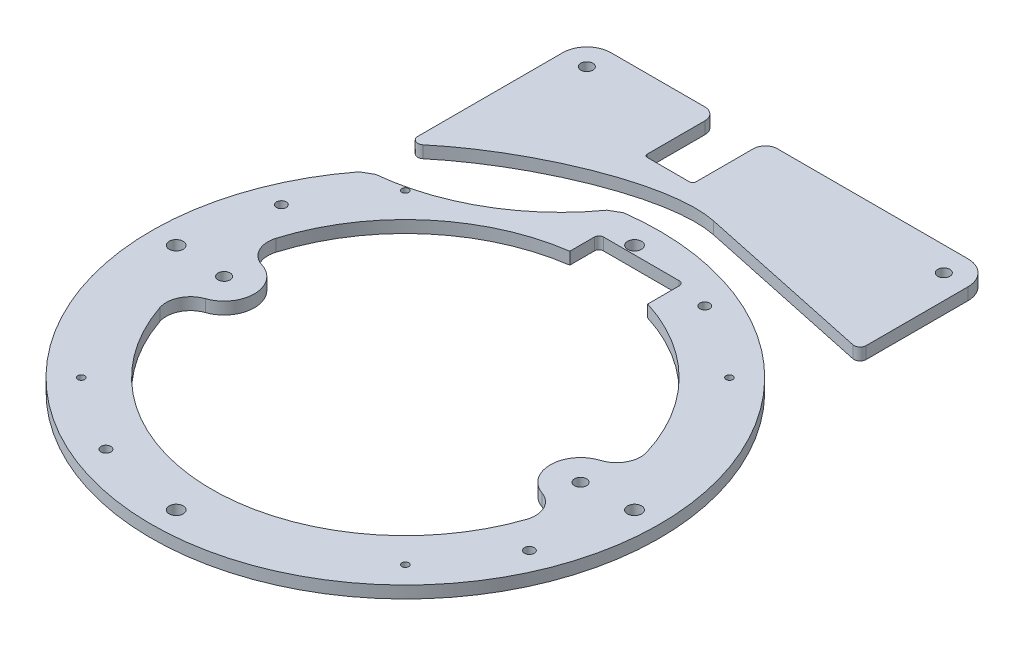
from build123d import *

# Parameters (mm, degrees)
SKETCH1_R           = 133.35
BOSS_EXTRUDE1_DEPTH = 19.05
SKETCH2_R           = 3.6703
SKETCH2_R_2         = 2.5781
SKETCH2_R_3         = 1.7859375
CUT_EXTRUDE1_DEPTH  = 20.05
BOSS_EXTRUDE2_DEPTH = 19.05
FILLET1_R           = 25.4
SKETCH4_R           = 3.175
CUT_EXTRUDE2_DEPTH  = 20.05
SKETCH5_R           = 7.9375
CUT_EXTRUDE3_DEPTH  = 12.7
CUT_EXTRUDE4_DEPTH  = 20.05
CUT_EXTRUDE5_DEPTH  = 12.7
FILLET2_R           = 3.175
CUT_EXTRUDE6_DEPTH  = 6.35
CUT_EXTRUDE8_DEPTH  = 12.7


with BuildPart() as part:
    # Sketch1 → Boss-Extrude1 (new body)
    with BuildSketch(Plane(origin=(0, 0, 0), x_dir=(1, 0, 0), z_dir=(0, 1, 0))):
        Circle(SKETCH1_R)
    extrude(amount=BOSS_EXTRUDE1_DEPTH)

    # Sketch2 → Cut-Extrude1 (cut, through all)
    with BuildSketch(Plane(origin=(0, 19.05, 0), x_dir=(1, 0, 0), z_dir=(0, 1, 0))):
        with Locations((-120.2563, 0)):
            Circle(SKETCH2_R)
        with Locations((-111.10233558, 46.02009338)):
            Circle(SKETCH2_R_2)
        with Locations((120.2563, 0)):
            Circle(SKETCH2_R)
        with Locations((0, -120.2563)):
            Circle(SKETCH2_R)
        with Locations((0, 120.2563)):
            Circle(SKETCH2_R)
        with Locations((111.10233558, -46.02009338)):
            Circle(SKETCH2_R_2)
        with Locations((-46.02009338, -111.10233558)):
            Circle(SKETCH2_R_2)
        with Locations((46.02009338, 111.10233558)):
            Circle(SKETCH2_R_2)
        with Locations((-85.03404521, -85.03404521)):
            Circle(SKETCH2_R_3)
        with Locations((85.03404521, 85.03404521)):
            Circle(SKETCH2_R_3)
        with Locations((-85.03404521, 85.03404521)):
            Circle(SKETCH2_R_3)
        with Locations((85.03404521, -85.03404521)):
            Circle(SKETCH2_R_3)
    extrude(amount=-CUT_EXTRUDE1_DEPTH, mode=Mode.SUBTRACT)

    # Sketch3 → Boss-Extrude2 (add)
    with BuildSketch(Plane(origin=(0, 19.05, 0), x_dir=(1, 0, 0), z_dir=(0, 1, 0))):
        with BuildLine():
            Line((-106.3625, 80.431592635), (-106.3625, 188.9125))
            ThreePointArc((-106.3625, 188.9125), (-102.642756121, 197.892756121), (-93.6625, 201.6125))
            Line((-93.6625, 201.6125), (93.6625, 201.6125))
            ThreePointArc((93.6625, 201.6125), (102.642756121, 197.892756121), (106.3625, 188.9125))
            Line((106.3625, 188.9125), (106.3625, 80.431592635))
            ThreePointArc((106.3625, 80.431592635), (0, 133.35), (-106.3625, 80.431592635))
        make_face()
    extrude(amount=-BOSS_EXTRUDE2_DEPTH)

    # Fillet1
    fillet1_edges = [part.edges().sort_by_distance(p)[0] for p in [
        (106.3625, 9.525, -80.431592635),
        (-106.3625, 9.525, -80.431592635),
    ]]
    fillet(fillet1_edges, radius=FILLET1_R)

    # Sketch4 → Cut-Extrude2 (cut, through all)
    with BuildSketch(Plane(origin=(0, 19.05, 0), x_dir=(1, 0, 0), z_dir=(0, 1, 0))):
        with Locations((-93.6625, 188.9125)):
            Circle(SKETCH4_R)
        with Locations((93.6625, 188.9125)):
            Circle(SKETCH4_R)
        with Locations((93.5355, -1.5875)):
            Circle(SKETCH4_R)
        with Locations((-93.5355, -1.5875)):
            Circle(SKETCH4_R)
        with BuildLine():
            Line((-38.1, 165.1), (-38.1, 195.2625))
            ThreePointArc((-38.1, 195.2625), (-39.959871939, 199.752628061), (-44.45, 201.6125))
            Line((-44.45, 201.6125), (-6.35, 201.6125))
            ThreePointArc((-6.35, 201.6125), (-10.840128061, 199.752628061), (-12.7, 195.2625))
            Line((-12.7, 195.2625), (-12.7, 165.1))
            ThreePointArc((-12.7, 165.1), (-13.164967985, 163.977467985), (-14.2875, 163.5125))
            Line((-14.2875, 163.5125), (-36.5125, 163.5125))
            ThreePointArc((-36.5125, 163.5125), (-37.635032015, 163.977467985), (-38.1, 165.1))
        make_face()
    extrude(amount=-CUT_EXTRUDE2_DEPTH, mode=Mode.SUBTRACT)

    # Sketch5 → Cut-Extrude3 (cut)
    with BuildSketch(Plane.XZ):
        with Locations((-93.5355, 1.5875)):
            Circle(SKETCH5_R)
        with Locations((-93.6625, -188.9125)):
            Circle(SKETCH5_R)
        with Locations((93.6625, -188.9125)):
            Circle(SKETCH5_R)
        with Locations((93.5355, 1.5875)):
            Circle(SKETCH5_R)
    extrude(amount=-CUT_EXTRUDE3_DEPTH, mode=Mode.SUBTRACT)

    # Sketch6 → Cut-Extrude4 (cut, through all)
    with BuildSketch(Plane.XZ):
        with BuildLine():
            ThreePointArc((-97.25707655, -29.387430322), (0, -101.6), (97.25707655, -29.387430322))
            ThreePointArc((97.25707655, -29.387430322), (96.312482934, -19.750032603), (88.849078878, -13.580000851))
            ThreePointArc((88.849078878, -13.580000851), (77.662785938, 1.318105668), (88.337075578, 16.587233615))
            ThreePointArc((88.337075578, 16.587233615), (95.586803849, 23.006979086), (96.203812617, 32.67088058))
            ThreePointArc((96.203812617, 32.67088058), (0, 101.6), (-96.203812617, 32.67088058))
            ThreePointArc((-96.203812617, 32.67088058), (-95.586803849, 23.006979086), (-88.337075578, 16.587233615))
            ThreePointArc((-88.337075578, 16.587233615), (-77.662785938, 1.318105668), (-88.849078878, -13.580000851))
            ThreePointArc((-88.849078878, -13.580000851), (-96.312482934, -19.750032603), (-97.25707655, -29.387430322))
        make_face()
    extrude(amount=-CUT_EXTRUDE4_DEPTH, mode=Mode.SUBTRACT)

    # Sketch7 → Cut-Extrude5 (cut)
    with BuildSketch(Plane(origin=(0, 19.05, 0), x_dir=(1, 0, 0), z_dir=(0, 1, 0))):
        with BuildLine():
            Line((106.3625, 131.527748149), (9.586053414, 152.098216886))
            add(Edge.make_bspline(
                [(9.586053414, 152.098216886), (-20.233717631, 158.436604889), (-75.860757578, 134.149121206), (-106.3625, 105.832753729)],
                knots=[0, 0, 0, 0, 1, 1, 1, 1], degree=3))
            Line((-106.3625, 105.832753729), (-110.6805, 74.377748149))
            ThreePointArc((-110.6805, 74.377748149), (-108.217560682, 77.917790395), (-105.641439401, 81.376340427))
            Line((-105.641439401, 81.376340427), (-100.142178087, 84.551340427))
            ThreePointArc((-100.142178087, 84.551340427), (-56.884848889, 98.527448456), (-23.15251969, 129.001340427))
            Line((-23.15251969, 129.001340427), (-17.653258376, 132.176340427))
            ThreePointArc((-17.653258376, 132.176340427), (54.760261489, 121.58756623), (110.6805, 74.377748149))
            Line((110.6805, 74.377748149), (106.3625, 131.527748149))
        make_face()
    extrude(amount=-CUT_EXTRUDE5_DEPTH, mode=Mode.SUBTRACT)

    # Fillet2
    fillet2_edges = [part.edges().sort_by_distance(p)[0] for p in [
        (-106.3625, 12.7, -105.832753729),
        (106.3625, 12.7, -131.527748149),
    ]]
    fillet(fillet2_edges, radius=FILLET2_R)

    # Sketch8 → Cut-Extrude6 (cut)
    with BuildSketch(Plane(origin=(0, 19.05, 0), x_dir=(1, 0, 0), z_dir=(0, 1, 0))):
        with BuildLine():
            Line((27.78125, 115.8875), (-11.90625, 115.8875))
            ThreePointArc((-11.90625, 115.8875), (-13.590048023, 115.190048023), (-14.2875, 113.50625))
            Line((-14.2875, 113.50625), (-14.2875, 84.1375))
            Line((-14.2875, 84.1375), (30.1625, 84.1375))
            Line((30.1625, 84.1375), (30.1625, 113.50625))
            ThreePointArc((30.1625, 113.50625), (29.465048023, 115.190048023), (27.78125, 115.8875))
        make_face()
    extrude(amount=-CUT_EXTRUDE6_DEPTH, mode=Mode.SUBTRACT)

    # Sketch10 → Cut-Extrude8 (cut)
    with BuildSketch(Plane.XZ):
        with BuildLine():
            Line((-93.6625, -201.6125), (-44.45, -201.6125))
            ThreePointArc((-44.45, -201.6125), (-39.959871939, -199.752628061), (-38.1, -195.2625))
            Line((-38.1, -195.2625), (-38.1, -165.1))
            ThreePointArc((-38.1, -165.1), (-37.635032015, -163.977467985), (-36.5125, -163.5125))
            Line((-36.5125, -163.5125), (-14.2875, -163.5125))
            ThreePointArc((-14.2875, -163.5125), (-13.164967985, -163.977467985), (-12.7, -165.1))
            Line((-12.7, -165.1), (-12.7, -195.2625))
            ThreePointArc((-12.7, -195.2625), (-10.840128061, -199.752628061), (-6.35, -201.6125))
            Line((-6.35, -201.6125), (93.6625, -201.6125))
            ThreePointArc((93.6625, -201.6125), (102.642756121, -197.892756121), (106.3625, -188.9125))
            Line((106.3625, -188.9125), (106.3625, -88.544938273))
            ThreePointArc((106.3625, -88.544938273), (107.465969383, -81.139629366), (110.6805, -74.377748149))
            ThreePointArc((110.6805, -74.377748149), (0, 133.35), (-110.6805, -74.377748149))
            ThreePointArc((-110.6805, -74.377748149), (-107.465969383, -81.139629366), (-106.3625, -88.544938273))
            Line((-106.3625, -88.544938273), (-106.3625, -188.9125))
            ThreePointArc((-106.3625, -188.9125), (-102.642756121, -197.892756121), (-93.6625, -201.6125))
        make_face()
    extrude(amount=-CUT_EXTRUDE8_DEPTH, mode=Mode.SUBTRACT)


solid = part.part
